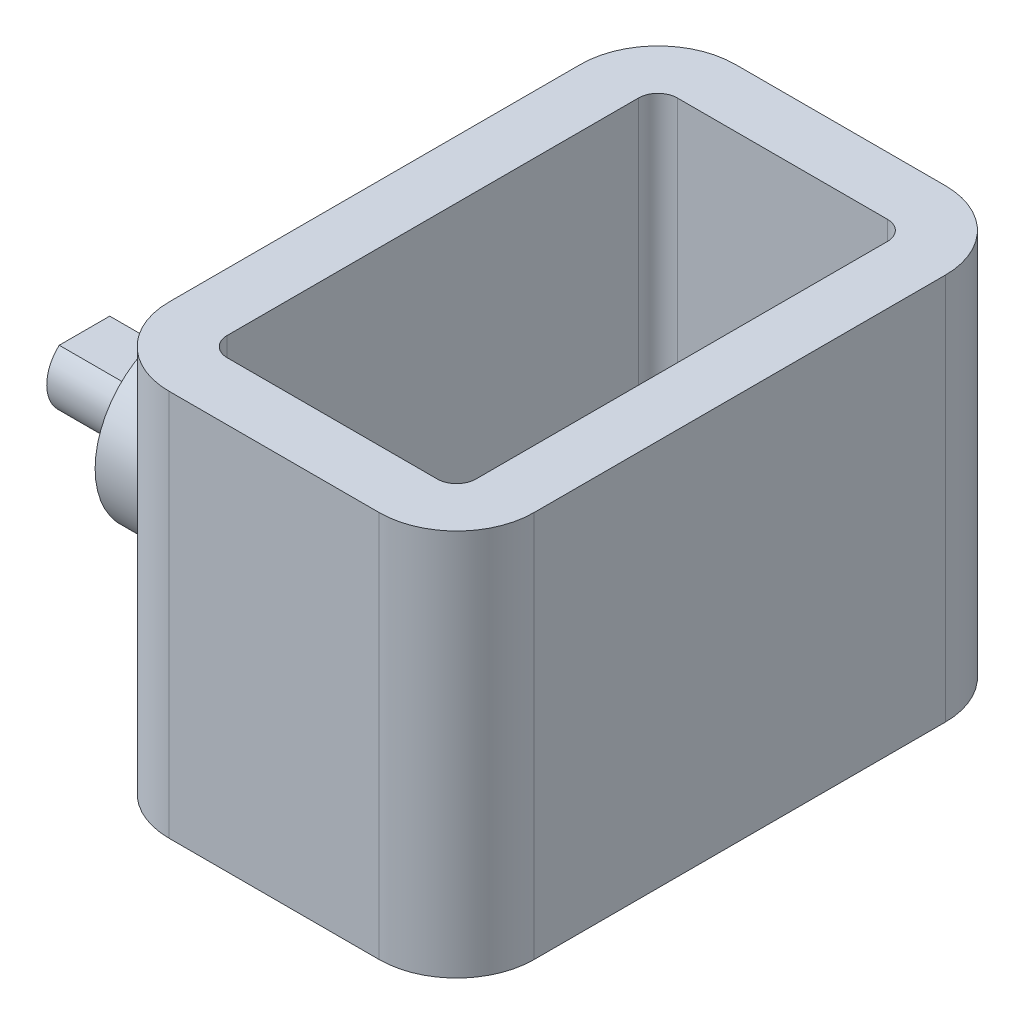
from build123d import *

# Parameters (mm, degrees)
BOSS_EXTRUDE1_DEPTH = 20
SKETCH2_R           = 4.45
BOSS_EXTRUDE2_DEPTH = 10
BOSS_EXTRUDE3_DEPTH = 15


with BuildPart() as part:
    # Sketch1 → Boss-Extrude1 (new body)
    with BuildSketch(Plane(origin=(0, 0, 0), x_dir=(1, 0, 0), z_dir=(0, 1, 0))):
        with BuildLine():
            Line((-5.425, 14.625), (5.425, 14.625))
            ThreePointArc((5.425, 14.625), (8.253427125, 13.453427125), (9.425, 10.625))
            Line((9.425, 10.625), (9.425, -10.625))
            ThreePointArc((9.425, -10.625), (8.253427125, -13.453427125), (5.425, -14.625))
            Line((5.425, -14.625), (-5.425, -14.625))
            ThreePointArc((-5.425, -14.625), (-8.253427125, -13.453427125), (-9.425, -10.625))
            Line((-9.425, -10.625), (-9.425, 10.625))
            ThreePointArc((-9.425, 10.625), (-8.253427125, 13.453427125), (-5.425, 14.625))
        make_face()
        with BuildLine():
            Line((-5.425, 11.625), (5.425, 11.625))
            ThreePointArc((5.425, 11.625), (6.132106781, 11.332106781), (6.425, 10.625))
            Line((6.425, 10.625), (6.425, -10.625))
            ThreePointArc((6.425, -10.625), (6.132106781, -11.332106781), (5.425, -11.625))
            Line((5.425, -11.625), (-5.425, -11.625))
            ThreePointArc((-5.425, -11.625), (-6.132106781, -11.332106781), (-6.425, -10.625))
            Line((-6.425, -10.625), (-6.425, 10.625))
            ThreePointArc((-6.425, 10.625), (-6.132106781, 11.332106781), (-5.425, 11.625))
        make_face(mode=Mode.SUBTRACT)
    extrude(amount=BOSS_EXTRUDE1_DEPTH)

    # Sketch2 → Boss-Extrude2 (add)
    with BuildSketch(Plane.ZY.offset(9.425)):
        with Locations((0, 4.45)):
            Circle(SKETCH2_R)
        with BuildLine():
            Line((-1.303840481, 5.9), (1.303840481, 5.9))
            ThreePointArc((1.303840481, 5.9), (0, 2.5), (-1.303840481, 5.9))
        make_face(mode=Mode.SUBTRACT)
    extrude(amount=BOSS_EXTRUDE2_DEPTH)

    # Sketch2_4 → Boss-Extrude3 (add)
    with BuildSketch(Plane.ZY.offset(9.425)):
        with BuildLine():
            ThreePointArc((1.95, 4.45), (1.78114976, 5.243728878), (1.303840481, 5.9))
            Line((1.303840481, 5.9), (-1.303840481, 5.9))
            ThreePointArc((-1.303840481, 5.9), (-0.793728878, 2.66885024), (1.95, 4.45))
        make_face()
    extrude(amount=BOSS_EXTRUDE3_DEPTH)


solid = part.part
